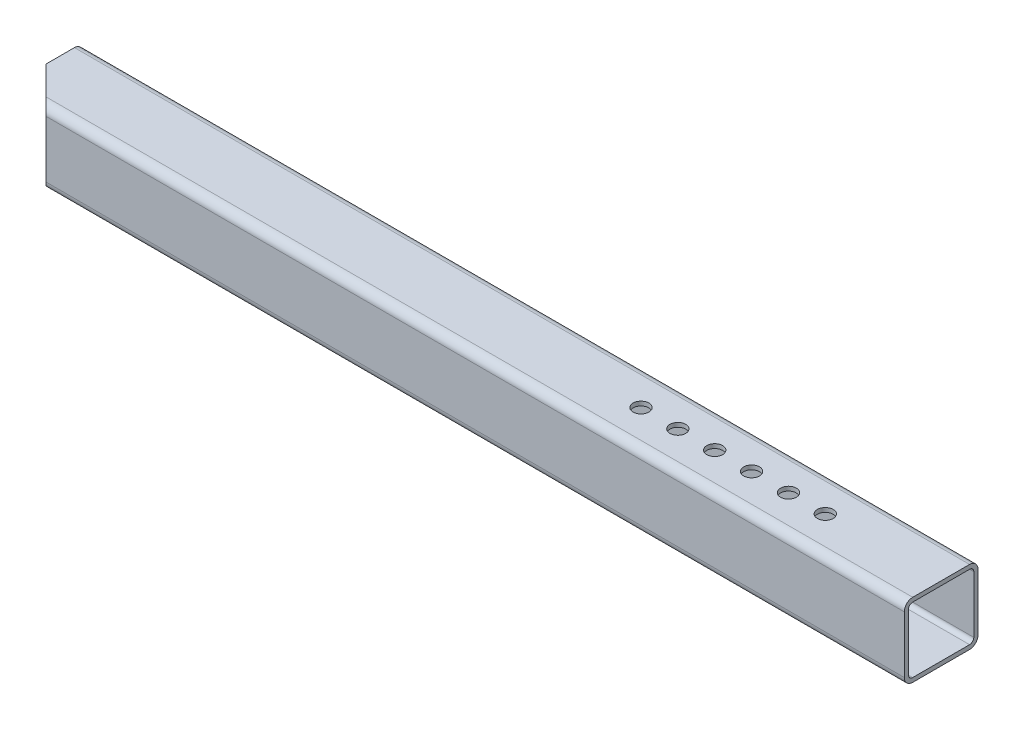
from build123d import *

# Parameters (mm, degrees)
EL_MENT_M_CANO_SOUD_1_DEPTH = 850
ESQUISSE3_R                 = 7.5
ENL_V_MAT_EXTRU_2_DEPTH     = 90
ENL_V_MAT_EXTRU_3_DEPTH     = 71
ESQUISSE6_R                 = 40.75
ENL_V_MAT_EXTRU_4_DEPTH     = 90


with BuildPart() as part:
    # tube carré1 → Elément mécano-soudé1 (new body)
    with BuildSketch(Plane.YZ.offset(-425)):
        with BuildLine():
            Line((-27, 35), (27, 35))
            ThreePointArc((27, 35), (32.656854249, 32.656854249), (35, 27))
            Line((35, 27), (35, -27))
            ThreePointArc((35, -27), (32.656854249, -32.656854249), (27, -35))
            Line((27, -35), (-27, -35))
            ThreePointArc((-27, -35), (-32.656854249, -32.656854249), (-35, -27))
            Line((-35, -27), (-35, 27))
            ThreePointArc((-35, 27), (-32.656854249, 32.656854249), (-27, 35))
        make_face()
        with BuildLine():
            Line((-27, 31), (27, 31))
            ThreePointArc((27, 31), (29.828427336, 29.828426914), (31, 26.999999403))
            Line((31, 26.999999403), (31, -26.999999403))
            ThreePointArc((31, -26.999999403), (29.828427336, -29.828426914), (27, -31))
            Line((27, -31), (-27, -31))
            ThreePointArc((-27, -31), (-29.828427336, -29.828426914), (-31, -26.999999403))
            Line((-31, -26.999999403), (-31, 26.999999403))
            ThreePointArc((-31, 26.999999403), (-29.828427336, 29.828426914), (-27, 31))
        make_face(mode=Mode.SUBTRACT)
    extrude(amount=EL_MENT_M_CANO_SOUD_1_DEPTH)

    # Esquisse3 → Enlèv. mat.-Extru.2 (cut)
    with BuildSketch(Plane(origin=(0, 35, 0), x_dir=(1, 0, 0), z_dir=(0, 1, 0))):
        with Locations(Location((315, 0, 0), (0, 0, 270))):  # turned: the seam where the file's is
            Circle(ESQUISSE3_R)
        with Locations(Location((280, 0, 0), (0, 0, 270))):  # turned: the seam where the file's is
            Circle(ESQUISSE3_R)
        with Locations(Location((245, 0, 0), (0, 0, 270))):  # turned: the seam where the file's is
            Circle(ESQUISSE3_R)
        with Locations(Location((210, 0, 0), (0, 0, 270))):  # turned: the seam where the file's is
            Circle(ESQUISSE3_R)
        with Locations(Location((175, 0, 0), (0, 0, 270))):  # turned: the seam where the file's is
            Circle(ESQUISSE3_R)
        with Locations(Location((140, 0, 0), (0, 0, 270))):  # turned: the seam where the file's is
            Circle(ESQUISSE3_R)
    extrude(amount=-ENL_V_MAT_EXTRU_2_DEPTH, mode=Mode.SUBTRACT)

    # Esquisse5 → Enlèv. mat.-Extru.3 (cut, through all)
    with BuildSketch(Plane(origin=(0, 35, 0), x_dir=(1, 0, 0), z_dir=(0, 1, 0))):
        Polygon((-425, 0), (-390, -35), (-425, -35), align=None)
    extrude(amount=-ENL_V_MAT_EXTRU_3_DEPTH, mode=Mode.SUBTRACT)

    # Esquisse6 → Enlèv. mat.-Extru.4 (cut, symmetric)
    with BuildSketch(Plane(origin=(0, 2.000000299, -2.000000299), x_dir=(1, 0, 0), z_dir=(0, -0.707106781, 0.707106781))):
        with Locations((-155, -56.183766184)):
            Circle(ESQUISSE6_R)
    extrude(amount=ENL_V_MAT_EXTRU_4_DEPTH, both=True, mode=Mode.SUBTRACT)


solid = part.part
